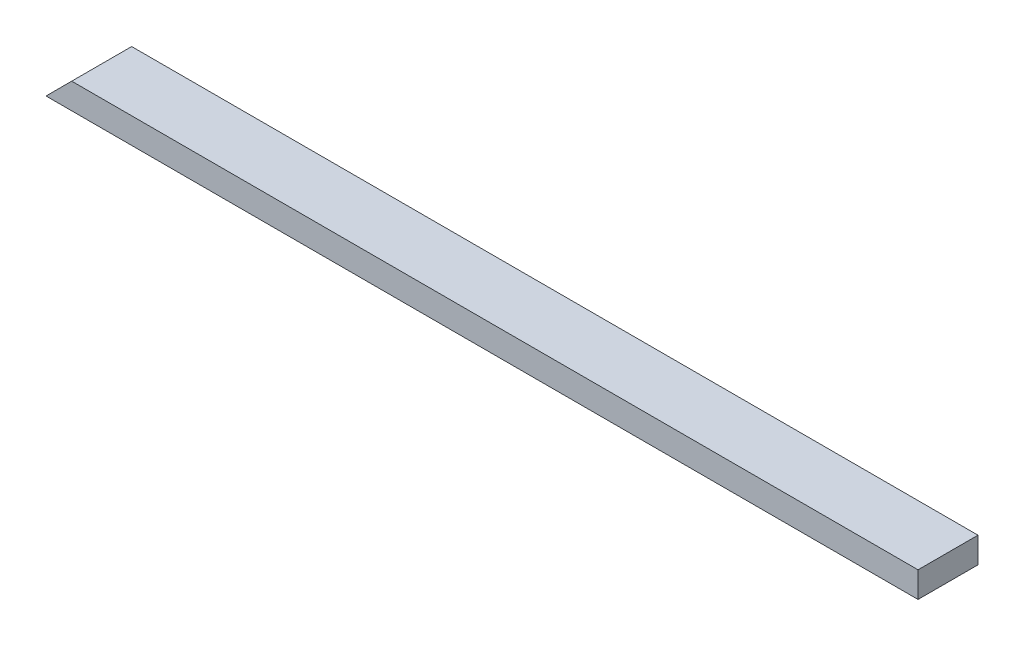
from build123d import *

# Parameters (mm, degrees)
SKETCH1_W           = 1292.8727
SKETCH1_H           = 88.9
BOSS_EXTRUDE1_DEPTH = 38.1
CUT_EXTRUDE1_DEPTH  = 89.9


with BuildPart() as part:
    # Sketch1 → Boss-Extrude1 (new body)
    with BuildSketch(Plane(origin=(0, 0, 0), x_dir=(1, 0, 0), z_dir=(0, 1, 0))):
        with Locations((646.43635, 44.45)):
            Rectangle(SKETCH1_W, SKETCH1_H)
    extrude(amount=BOSS_EXTRUDE1_DEPTH)

    # Sketch2 → Cut-Extrude1 (cut, through all)
    with BuildSketch(Plane.XY):
        Polygon((0, 0), (38.1, 38.1), (0, 38.1), align=None)
    extrude(amount=-CUT_EXTRUDE1_DEPTH, mode=Mode.SUBTRACT)


solid = part.part
